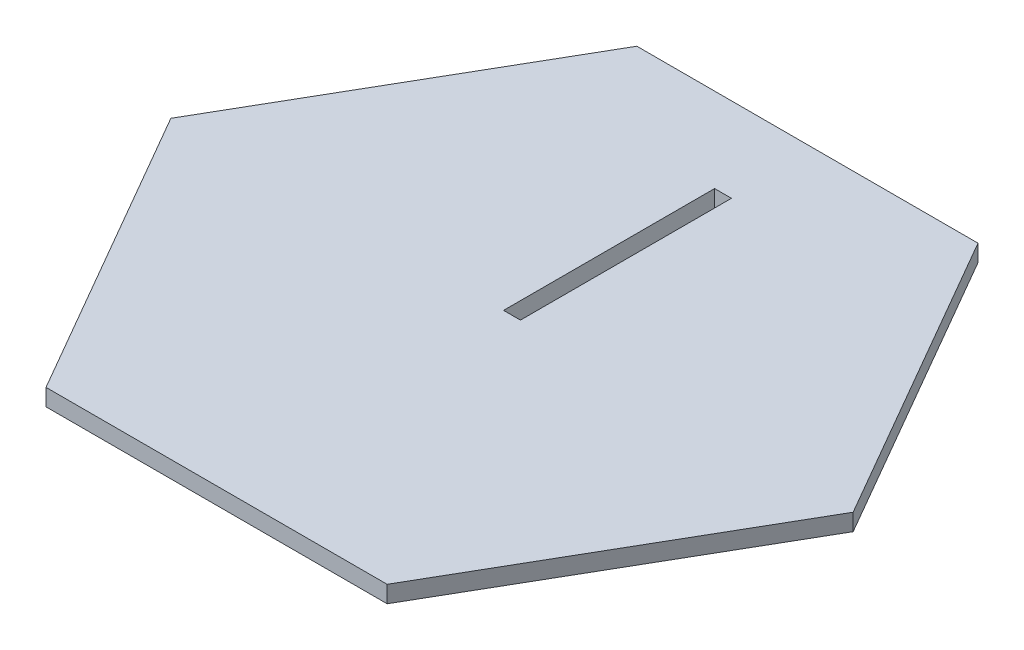
from build123d import *

# Parameters (mm, degrees)
BOSS_EXTRUDE1_DEPTH          = 2
SKETCH2_W                    = 2
SKETCH2_H                    = 25
CUT_EXTRUDE_THIN1_DEPTH      = 1
CUT_EXTRUDE_THIN1_DEPTH_BACK = 3


with BuildPart() as part:
    # Sketch1 → Boss-Extrude1 (new body)
    with BuildSketch(Plane(origin=(0, 0, 0), x_dir=(1, 0, 0), z_dir=(0, 1, 0))):
        Polygon((-20.207259422, -35), (20.207259422, -35), (40.414518843, 0), (20.207259422, 35), (-20.207259422, 35), (-40.414518843, 0), align=None)
    extrude(amount=BOSS_EXTRUDE1_DEPTH)

    # Sketch2 → Cut-Extrude-Thin1 (cut, two sides)
    with BuildSketch(Plane(origin=(0, 2, 0), x_dir=(1, 0, 0), z_dir=(0, 1, 0))) as cut_extrude_thin1_sk:
        with Locations((0, 12.5)):
            Rectangle(SKETCH2_W, SKETCH2_H)
    extrude(amount=CUT_EXTRUDE_THIN1_DEPTH, mode=Mode.SUBTRACT)
    extrude(cut_extrude_thin1_sk.sketch, amount=-CUT_EXTRUDE_THIN1_DEPTH_BACK, mode=Mode.SUBTRACT)


solid = part.part
